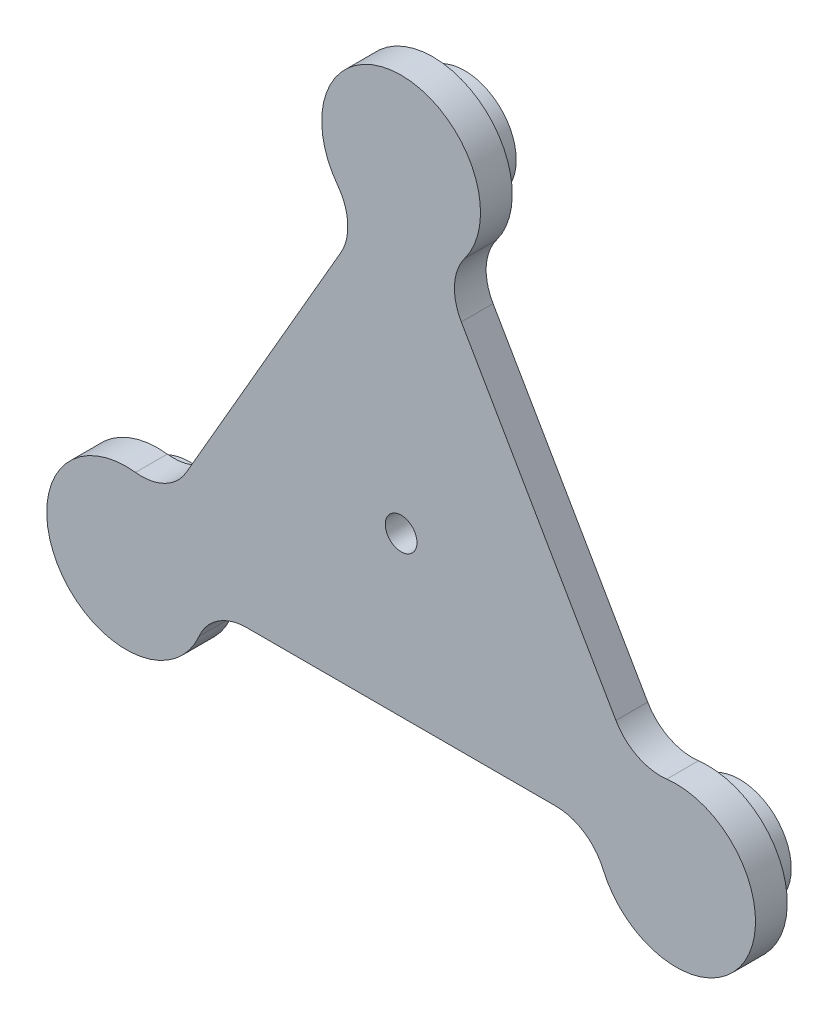
from build123d import *

# Parameters (mm, degrees)
BOSS_EXTRUDE1_DEPTH = 10
SKETCH2_R           = 16.25
BOSS_EXTRUDE2_DEPTH = 10
SKETCH3_R           = 5
CUT_EXTRUDE1_DEPTH  = 10


with BuildPart() as part:
    # Sketch1 → Boss-Extrude1 (new body)
    with BuildSketch(Plane(origin=(0, 0, 0), x_dir=(1, 0, 0), z_dir=(0, 0, -1))):
        with BuildLine():
            Line((18.95720217, -67.165147363), (67.645318019, 17.165182331))
            ThreePointArc((67.645318019, 17.165182331), (74.442164244, 23.570200009), (83.642337861, 25.175869802))
            ThreePointArc((83.642337861, 25.175869802), (108.253132571, 62.500004371), (63.624087575, 59.848480209))
            ThreePointArc((63.624087575, 59.848480209), (57.63345283, 52.683728615), (48.68812278, 49.999992345))
            Line((48.68812278, 49.999992345), (-48.688142969, 49.999972686))
            ThreePointArc((-48.688142969, 49.999972686), (-57.633474102, 52.683705343), (-63.624111741, 59.848454519))
            ThreePointArc((-63.624111741, 59.848454519), (-108.253157807, 62.49996066), (-83.642348027, 25.175836028))
            ThreePointArc((-83.642348027, 25.175836028), (-74.442173761, 23.570169951), (-67.64532495, 17.165155017))
            Line((-67.64532495, 17.165155017), (-18.95717505, -67.165155017))
            ThreePointArc((-18.95717505, -67.165155017), (-16.808690142, -76.253905353), (-20.01822612, -85.02432432))
            ThreePointArc((-20.01822612, -85.02432432), (2.5237e-05, -124.999965031), (20.018260452, -85.024316237))
            ThreePointArc((20.018260452, -85.024316237), (16.808720932, -76.253898566), (18.95720217, -67.165147363))
        make_face()
    extrude(amount=BOSS_EXTRUDE1_DEPTH)

    # Sketch2 → Boss-Extrude2 (add)
    with BuildSketch(Plane(origin=(0, 0, -10), x_dir=(1, 0, 0), z_dir=(0, 0, -1))):
        with Locations((86.6025, 50)):
            Circle(SKETCH2_R)
        with Locations((2.0189e-05, -99.999965031)):
            Circle(SKETCH2_R)
        with Locations((-86.602520189, 49.999965031)):
            Circle(SKETCH2_R)
    extrude(amount=BOSS_EXTRUDE2_DEPTH)

    # Sketch3 → Cut-Extrude1 (cut)
    with BuildSketch(Plane.XY):
        Circle(SKETCH3_R)
    extrude(amount=-CUT_EXTRUDE1_DEPTH, mode=Mode.SUBTRACT)


solid = part.part
